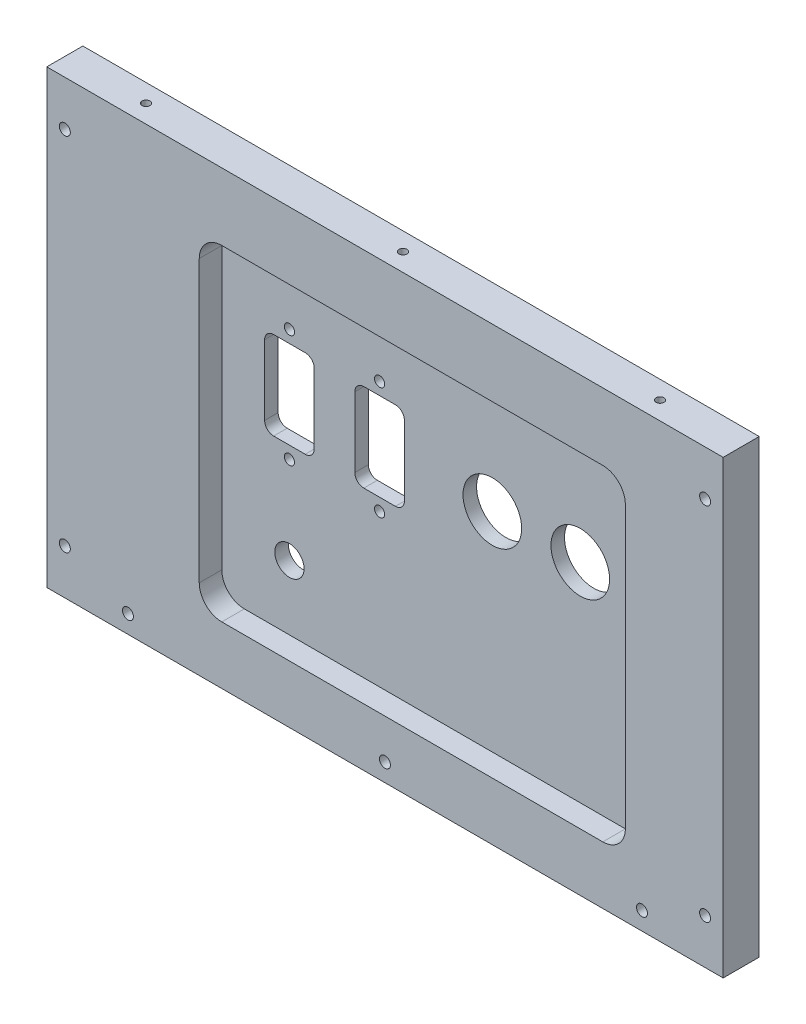
from build123d import *

# Parameters (mm, degrees)
SKETCH1_W                                      = 150
SKETCH1_H                                      = 100
BOSS_EXTRUDE1_DEPTH                            = 8
CBORE_FOR_2_SOCKET_HEAD_CAP_SCREW1_D           = 2.4384
CBORE_FOR_2_SOCKET_HEAD_CAP_SCREW1_CBORE_D     = 4.7625
CBORE_FOR_2_SOCKET_HEAD_CAP_SCREW1_CBORE_DEPTH = 2.1844
F_2_56_TAPPED_HOLE1_D                          = 1.778
F_2_56_TAPPED_HOLE1_DEPTH                      = 20
F_2_56_TAPPED_HOLE1_TIP                        = 0.53416509
SKETCH7_R                                      = 6.5
SKETCH7_R_2                                    = 3.25
BNC_PIEZO_BNC_THRU_HOLES_DEPTH                 = 9
F_4_40_TAPPED_HOLE1_D                          = 2.2606
F_4_40_TAPPED_HOLE1_CSINK_D                    = 4.1148
F_4_40_TAPPED_HOLE1_CSINK_ANGLE                = 90
SKETCH7_3_R                                    = 6.5
SKETCH7_3_R_2                                  = 3.25
CUT_EXTRUDE2_DEPTH                             = 5


with BuildPart() as part:
    # Sketch1 → Boss-Extrude1 (new body)
    with BuildSketch(Plane.XY):
        with Locations((75, 50)):
            Rectangle(SKETCH1_W, SKETCH1_H)
    extrude(amount=BOSS_EXTRUDE1_DEPTH)

    # CBORE for _2 Socket Head Cap Screw1 (through all)
    with Locations(Plane(origin=(0, 0, 0), x_dir=(-1, 0, 0), z_dir=(0, 0, -1))):
        with Locations((-132, 4), (-18, 4), (-4, 90), (-146, 90), (-146, 10), (-4, 10), (-75, 4)):
            CounterBoreHole(CBORE_FOR_2_SOCKET_HEAD_CAP_SCREW1_D / 2, CBORE_FOR_2_SOCKET_HEAD_CAP_SCREW1_CBORE_D / 2, CBORE_FOR_2_SOCKET_HEAD_CAP_SCREW1_CBORE_DEPTH)

    # 2-56 Tapped Hole1
    with Locations(Plane(origin=(0, 100, 0), x_dir=(1, 0, 0), z_dir=(0, 1, 0))):
        with Locations((18, -4), (75, -4), (132, -4)):
            Hole(F_2_56_TAPPED_HOLE1_D / 2, depth=F_2_56_TAPPED_HOLE1_DEPTH)
            with Locations((0, 0, -(F_2_56_TAPPED_HOLE1_DEPTH + F_2_56_TAPPED_HOLE1_TIP / 2))):  # 118° drill point
                Cone(0, F_2_56_TAPPED_HOLE1_D / 2, F_2_56_TAPPED_HOLE1_TIP, mode=Mode.SUBTRACT)

    # Sketch7 → BNC _ piezo _ BNC thru holes (cut, through all)
    with BuildSketch(Plane.XY.offset(8)):
        with BuildLine():
            Line((45.313838353, 68.75), (52.313838353, 68.75))
            ThreePointArc((52.313838353, 68.75), (53.728051916, 68.164213562), (54.313838353, 66.75))
            Line((54.313838353, 66.75), (54.313838353, 51.25))
            ThreePointArc((54.313838353, 51.25), (53.728051916, 49.835786438), (52.313838353, 49.25))
            Line((52.313838353, 49.25), (45.313838353, 49.25))
            ThreePointArc((45.313838353, 49.25), (43.899624791, 49.835786438), (43.313838353, 51.25))
            Line((43.313838353, 51.25), (43.313838353, 66.75))
            ThreePointArc((43.313838353, 66.75), (43.899624791, 68.164213562), (45.313838353, 68.75))
        make_face()
        with BuildLine():
            Line((65.313838353, 68.75), (72.313838353, 68.75))
            ThreePointArc((72.313838353, 68.75), (73.728051916, 68.164213562), (74.313838353, 66.75))
            Line((74.313838353, 66.75), (74.313838353, 51.25))
            ThreePointArc((74.313838353, 51.25), (73.728051916, 49.835786438), (72.313838353, 49.25))
            Line((72.313838353, 49.25), (65.313838353, 49.25))
            ThreePointArc((65.313838353, 49.25), (63.899624791, 49.835786438), (63.313838353, 51.25))
            Line((63.313838353, 51.25), (63.313838353, 66.75))
            ThreePointArc((63.313838353, 66.75), (63.899624791, 68.164213562), (65.313838353, 68.75))
        make_face()
        with Locations((93.813838353, 59)):
            Circle(SKETCH7_R)
        with Locations((113.313838353, 59)):
            Circle(SKETCH7_R)
        with Locations((48.813838353, 27.1)):
            Circle(SKETCH7_R_2)
    extrude(amount=-BNC_PIEZO_BNC_THRU_HOLES_DEPTH, mode=Mode.SUBTRACT)

    # 4-40 Tapped Hole1 (through all)
    with Locations(Plane.XY.offset(8)):
        with Locations((48.813838353, 71.5), (68.813838353, 71.5), (68.813838353, 46.5), (48.813838353, 46.5)):
            CounterSinkHole(F_4_40_TAPPED_HOLE1_D / 2, F_4_40_TAPPED_HOLE1_CSINK_D / 2, counter_sink_angle=F_4_40_TAPPED_HOLE1_CSINK_ANGLE)

    # Sketch7_3 → Cut-Extrude2 (cut)
    with BuildSketch(Plane.XY.offset(8)):
        with BuildLine():
            Line((38.813838353, 85.1), (123.313838353, 85.1))
            ThreePointArc((123.313838353, 85.1), (126.849372259, 83.635533906), (128.313838353, 80.1))
            Line((128.313838353, 80.1), (128.313838353, 17.8))
            ThreePointArc((128.313838353, 17.8), (126.849372259, 14.264466094), (123.313838353, 12.8))
            Line((123.313838353, 12.8), (38.813838353, 12.8))
            ThreePointArc((38.813838353, 12.8), (35.278304447, 14.264466094), (33.813838353, 17.8))
            Line((33.813838353, 17.8), (33.813838353, 80.1))
            ThreePointArc((33.813838353, 80.1), (35.278304447, 83.635533906), (38.813838353, 85.1))
        make_face()
        with Locations((93.813838353, 59)):
            Circle(SKETCH7_3_R, mode=Mode.SUBTRACT)
        with Locations((113.313838353, 59)):
            Circle(SKETCH7_3_R, mode=Mode.SUBTRACT)
        with Locations((48.813838353, 27.1)):
            Circle(SKETCH7_3_R_2, mode=Mode.SUBTRACT)
        with BuildLine():
            Line((45.313838353, 68.75), (52.313838353, 68.75))
            ThreePointArc((52.313838353, 68.75), (53.728051916, 68.164213562), (54.313838353, 66.75))
            Line((54.313838353, 66.75), (54.313838353, 51.25))
            ThreePointArc((54.313838353, 51.25), (53.728051916, 49.835786438), (52.313838353, 49.25))
            Line((52.313838353, 49.25), (45.313838353, 49.25))
            ThreePointArc((45.313838353, 49.25), (43.899624791, 49.835786438), (43.313838353, 51.25))
            Line((43.313838353, 51.25), (43.313838353, 66.75))
            ThreePointArc((43.313838353, 66.75), (43.899624791, 68.164213562), (45.313838353, 68.75))
        make_face(mode=Mode.SUBTRACT)
        with BuildLine():
            Line((65.313838353, 68.75), (72.313838353, 68.75))
            ThreePointArc((72.313838353, 68.75), (73.728051916, 68.164213562), (74.313838353, 66.75))
            Line((74.313838353, 66.75), (74.313838353, 51.25))
            ThreePointArc((74.313838353, 51.25), (73.728051916, 49.835786438), (72.313838353, 49.25))
            Line((72.313838353, 49.25), (65.313838353, 49.25))
            ThreePointArc((65.313838353, 49.25), (63.899624791, 49.835786438), (63.313838353, 51.25))
            Line((63.313838353, 51.25), (63.313838353, 66.75))
            ThreePointArc((63.313838353, 66.75), (63.899624791, 68.164213562), (65.313838353, 68.75))
        make_face(mode=Mode.SUBTRACT)
    extrude(amount=-CUT_EXTRUDE2_DEPTH, mode=Mode.SUBTRACT)


solid = part.part
